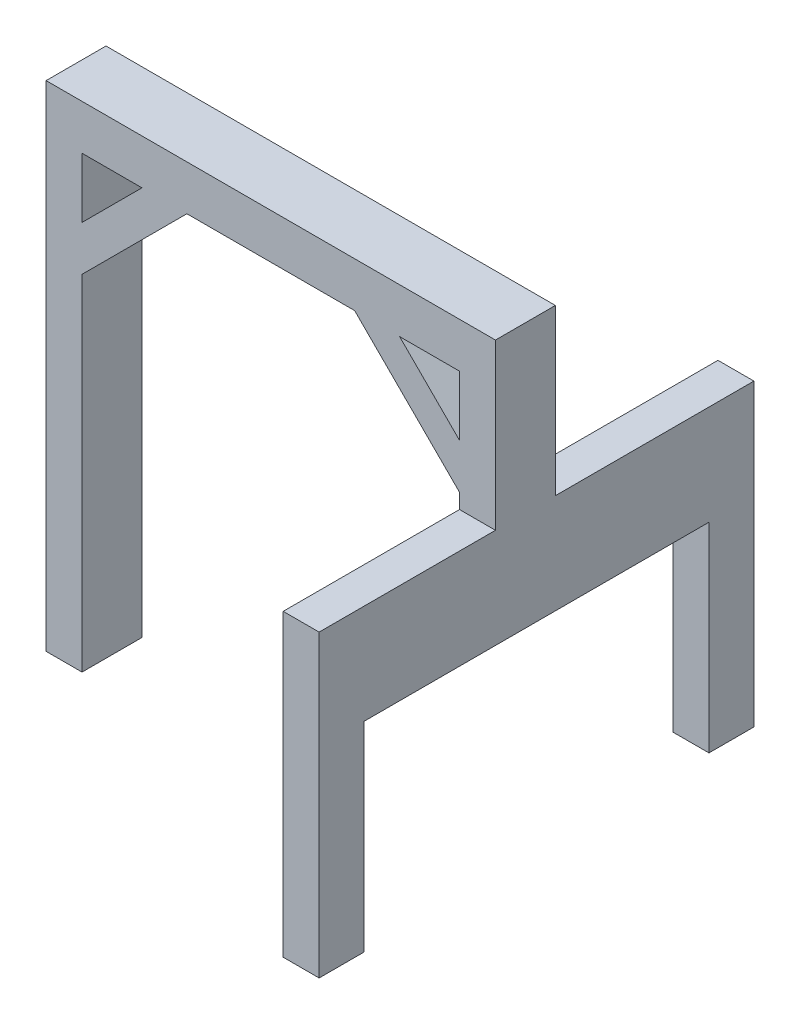
from build123d import *

# Parameters (mm, degrees)
BOSS_EXTRUDE2_DEPTH = 20
SKETCH2_W           = 15
SKETCH2_H           = 100
BOSS_EXTRUDE3_DEPTH = 12


with BuildPart() as part:
    # Sketch1 → Boss-Extrude2 (new body)
    with BuildSketch(Plane.XY):
        Polygon((87.329047187, 46.385009916), (-62.670952813, 46.385009916), (-62.670952813, -118.614990084), (-50.670952813, -118.614990084), (-50.670952813, -3.614990084), (-15.670952813, 31.385009916), (40.329047187, 31.385009916), (75.329047187, -3.614990084), (75.329047187, -8.614990084), (87.329047187, -8.614990084), align=None)
        Polygon((75.329047187, 11.385009916), (55.329047187, 31.385009916), (75.329047187, 31.385009916), align=None, mode=Mode.SUBTRACT)
        Polygon((-50.670952813, 31.385009916), (-30.670952813, 31.385009916), (-50.670952813, 11.385009916), align=None, mode=Mode.SUBTRACT)
    extrude(amount=BOSS_EXTRUDE2_DEPTH)

    # Sketch2 → Boss-Extrude3 (add)
    with BuildSketch(Plane(origin=(87.329047187, 0, 0), x_dir=(0, 0, -1), z_dir=(1, 0, 0))):
        Polygon((-20, -8.614990084), (-63.858795675, -8.614990084), (-63.858795675, -41.914961686), (51.271272263, -41.914961686), (51.271272263, -8.614990084), (0, -8.614990084), align=None)
        Polygon((-63.858795675, -41.914961686), (-63.858795675, -8.614990084), (-78.858795675, -8.614990084), (-78.858795675, -108.614990084), (-63.858795675, -108.614990084), align=None)
        with Locations((58.771272263, -58.614990084)):
            Rectangle(SKETCH2_W, SKETCH2_H)
    extrude(amount=-BOSS_EXTRUDE3_DEPTH)


solid = part.part
